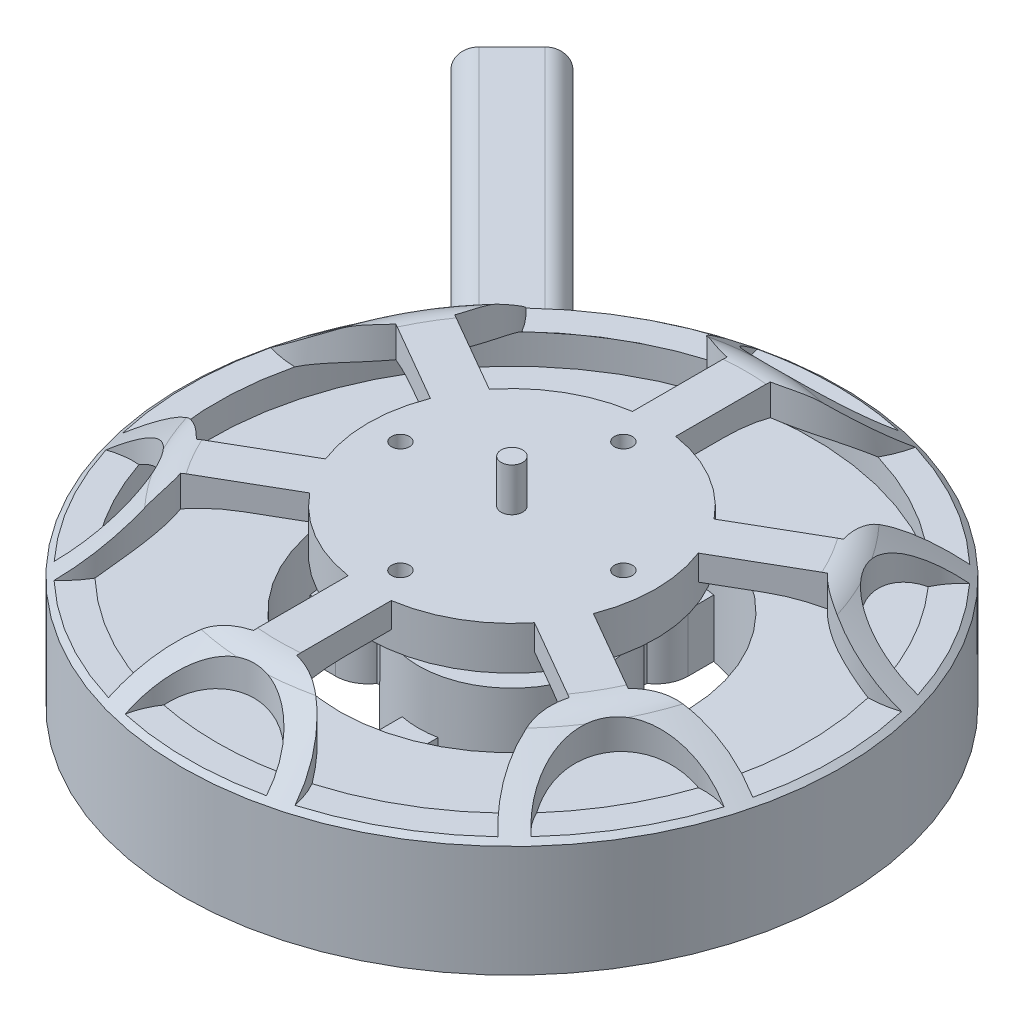
from build123d import *

# Parameters (mm, degrees)
M4X0_7_TAPPED_HOLE1_D     = 3.3
M4X0_7_TAPPED_HOLE1_DEPTH = 8.000009
M4X0_7_TAPPED_HOLE1_TIP   = 0.99142
CUT_EXTRUDE1_DEPTH        = 8
CUT_EXTRUDE3_START        = 32.18
SKETCH6_OUTSIDE_W         = 120.686
SKETCH6_OUTSIDE_H         = 120.686
CUT_EXTRUDE3_DEPTH        = 8
M3X0_5_TAPPED_HOLE1_D     = 2.5
M3X0_5_TAPPED_HOLE1_DEPTH = 6
BOSS_EXTRUDE1_START       = 12.7
BOSS_EXTRUDE1_DEPTH       = 19.05


with BuildPart() as part:
    # Sketch1 → Revolve1 (revolve)
    with BuildSketch(Plane.XY):
        with BuildLine():
            Line((0, 0), (9.65, 0))
            Line((9.65, 0), (9.65, 3.93))
            Line((9.65, 3.93), (27.5, 3.93))
            Line((27.5, 3.93), (45.83, 8.08))
            Line((45.83, 8.08), (45.83, 23.58))
            Line((45.83, 23.58), (36.13217, 30.955703))
            ThreePointArc((36.13217, 30.955703), (34.416479, 31.865693), (32.5, 32.18))
            Line((32.5, 32.18), (1.5, 32.18))
            Line((1.5, 32.18), (1.5, 38.18))
            Line((1.5, 38.18), (0, 38.18))
            Line((0, 38.18), (0, 0))
        make_face()
    revolve(axis=Axis((0, 38.18, 0), (0, -1, 0)))

    # M4x0.7 Tapped Hole1
    with Locations(Plane(origin=(-20, 3.93, 0), x_dir=(0, 0, -1), z_dir=(0, -1, 0))):
        with Locations((0, 0), (-20, 20), (0, 40), (20, 20)):
            Hole(M4X0_7_TAPPED_HOLE1_D / 2, depth=M4X0_7_TAPPED_HOLE1_DEPTH)
            with Locations((0, 0, -(M4X0_7_TAPPED_HOLE1_DEPTH + M4X0_7_TAPPED_HOLE1_TIP / 2))):  # 118° drill point
                Cone(0, M4X0_7_TAPPED_HOLE1_D / 2, M4X0_7_TAPPED_HOLE1_TIP, mode=Mode.SUBTRACT)

    # Sketch2 → Cut-Extrude1 (cut)
    with BuildSketch(Plane.XZ.offset(-3.93)):
        with BuildLine():
            Line((2.5, 12.757351), (2.5, 16.258343))
            ThreePointArc((2.5, 16.258343), (3.968627, 17.87868), (4.5, 20))
            Line((4.5, 20), (4.5, 23.57435))
            ThreePointArc((4.5, 23.57435), (16.970563, 16.970563), (23.57435, 4.5))
            Line((23.57435, 4.5), (20, 4.5))
            ThreePointArc((20, 4.5), (17.87868, 3.968627), (16.258343, 2.5))
            Line((16.258343, 2.5), (12.757351, 2.5))
            ThreePointArc((12.757351, 2.5), (9.192388, 9.192388), (2.5, 12.757351))
        make_face()
        with BuildLine():
            Line((20, -4.5), (23.57435, -4.5))
            ThreePointArc((23.57435, -4.5), (16.970563, -16.970563), (4.5, -23.57435))
            Line((4.5, -23.57435), (4.5, -20))
            ThreePointArc((4.5, -20), (3.968627, -17.87868), (2.5, -16.258343))
            Line((2.5, -16.258343), (2.5, -12.757351))
            ThreePointArc((2.5, -12.757351), (9.192388, -9.192388), (12.757351, -2.5))
            Line((12.757351, -2.5), (16.258343, -2.5))
            ThreePointArc((16.258343, -2.5), (17.87868, -3.968627), (20, -4.5))
        make_face()
        with BuildLine():
            Line((-4.5, -20), (-4.5, -23.57435))
            ThreePointArc((-4.5, -23.57435), (-16.970563, -16.970563), (-23.57435, -4.5))
            Line((-23.57435, -4.5), (-20, -4.5))
            ThreePointArc((-20, -4.5), (-17.87868, -3.968627), (-16.258343, -2.5))
            Line((-16.258343, -2.5), (-12.757351, -2.5))
            ThreePointArc((-12.757351, -2.5), (-9.192388, -9.192388), (-2.5, -12.757351))
            Line((-2.5, -12.757351), (-2.5, -16.258343))
            ThreePointArc((-2.5, -16.258343), (-3.968627, -17.87868), (-4.5, -20))
        make_face()
        with BuildLine():
            Line((-20, 4.5), (-23.57435, 4.5))
            ThreePointArc((-23.57435, 4.5), (-16.970563, 16.970563), (-4.5, 23.57435))
            Line((-4.5, 23.57435), (-4.5, 20))
            ThreePointArc((-4.5, 20), (-3.968627, 17.87868), (-2.5, 16.258343))
            Line((-2.5, 16.258343), (-2.5, 12.757351))
            ThreePointArc((-2.5, 12.757351), (-9.192388, 9.192388), (-12.757351, 2.5))
            Line((-12.757351, 2.5), (-16.258343, 2.5))
            ThreePointArc((-16.258343, 2.5), (-17.87868, 3.968627), (-20, 4.5))
        make_face()
    extrude(amount=-CUT_EXTRUDE1_DEPTH, mode=Mode.SUBTRACT)

    # Sketch5 → Cut-Revolve3 (revolve, cut)
    with BuildSketch(Plane.XY):
        with BuildLine():
            Line((24, 19.43), (41.83, 19.43))
            Line((41.83, 19.43), (41.83, 23.58))
            ThreePointArc((41.83, 23.58), (34.683019, 27.370707), (26.699628, 28.68))
            Line((26.699628, 28.68), (20, 28.68))
            Line((20, 28.68), (20, 26.18))
            Line((20, 26.18), (10, 26.18))
            Line((10, 26.18), (10, 19.43))
            Line((10, 19.43), (13, 19.43))
            Line((13, 19.43), (13, 11.93))
            Line((13, 11.93), (24, 11.93))
            Line((24, 11.93), (24, 19.43))
        make_face()
    revolve(axis=Axis((0, 40.089, 0), (0, -1, 0)), mode=Mode.SUBTRACT)

    # Sketch6 outside → Cut-Extrude3 (cut)
    with BuildSketch(Plane(origin=(0, 0, 0), x_dir=(1, 0, 0), z_dir=(0, 1, 0)).offset(CUT_EXTRUDE3_START)):
        Rectangle(SKETCH6_OUTSIDE_W, SKETCH6_OUTSIDE_H)
        with BuildLine():
            Line((-3, 19.77372), (-3, 32.924091))
            ThreePointArc((-3, 32.924091), (-9.751293, 36.859226), (-13.11083, 43.914633))
            ThreePointArc((-13.11083, 43.914633), (-11.532938, 44.35516), (-9.940309, 44.739012))
            ThreePointArc((-9.940309, 44.739012), (0, 35.83), (9.940309, 44.739012))
            ThreePointArc((9.940309, 44.739012), (11.532938, 44.35516), (13.11083, 43.914633))
            ThreePointArc((13.11083, 43.914633), (9.751293, 36.859226), (3, 32.924091))
            Line((3, 32.924091), (3, 19.77372))
            ThreePointArc((3, 19.77372), (10, 17.320508), (15.624544, 12.484936))
            Line((15.624544, 12.484936), (27.013099, 19.060121))
            ThreePointArc((27.013099, 19.060121), (27.04538, 26.874481), (31.475773, 33.311629))
            ThreePointArc((31.475773, 33.311629), (32.646227, 32.165397), (33.774966, 30.978066))
            ThreePointArc((33.774966, 30.978066), (31.02969, 17.915), (43.715275, 13.760946))
            ThreePointArc((43.715275, 13.760946), (44.179165, 12.189763), (44.586603, 10.603005))
            ThreePointArc((44.586603, 10.603005), (36.796673, 9.984745), (30.013099, 13.863969))
            Line((30.013099, 13.863969), (18.624544, 7.288784))
            ThreePointArc((18.624544, 7.288784), (20, 0), (18.624544, -7.288784))
            Line((18.624544, -7.288784), (30.013099, -13.863969))
            ThreePointArc((30.013099, -13.863969), (36.796673, -9.984745), (44.586603, -10.603005))
            ThreePointArc((44.586603, -10.603005), (44.179165, -12.189763), (43.715275, -13.760946))
            ThreePointArc((43.715275, -13.760946), (31.02969, -17.915), (33.774966, -30.978066))
            ThreePointArc((33.774966, -30.978066), (32.646227, -32.165397), (31.475773, -33.311629))
            ThreePointArc((31.475773, -33.311629), (27.04538, -26.874481), (27.013099, -19.060121))
            Line((27.013099, -19.060121), (15.624544, -12.484936))
            ThreePointArc((15.624544, -12.484936), (10, -17.320508), (3, -19.77372))
            Line((3, -19.77372), (3, -32.924091))
            ThreePointArc((3, -32.924091), (9.751293, -36.859226), (13.11083, -43.914633))
            ThreePointArc((13.11083, -43.914633), (11.532938, -44.35516), (9.940309, -44.739012))
            ThreePointArc((9.940309, -44.739012), (0, -35.83), (-9.940309, -44.739012))
            ThreePointArc((-9.940309, -44.739012), (-11.532938, -44.35516), (-13.11083, -43.914633))
            ThreePointArc((-13.11083, -43.914633), (-9.751293, -36.859226), (-3, -32.924091))
            Line((-3, -32.924091), (-3, -19.77372))
            ThreePointArc((-3, -19.77372), (-10, -17.320508), (-15.624544, -12.484936))
            Line((-15.624544, -12.484936), (-27.013099, -19.060121))
            ThreePointArc((-27.013099, -19.060121), (-27.04538, -26.874481), (-31.475773, -33.311629))
            ThreePointArc((-31.475773, -33.311629), (-32.646227, -32.165397), (-33.774966, -30.978066))
            ThreePointArc((-33.774966, -30.978066), (-31.02969, -17.915), (-43.715275, -13.760946))
            ThreePointArc((-43.715275, -13.760946), (-44.179165, -12.189763), (-44.586603, -10.603005))
            ThreePointArc((-44.586603, -10.603005), (-36.796673, -9.984745), (-30.013099, -13.863969))
            Line((-30.013099, -13.863969), (-18.624544, -7.288784))
            ThreePointArc((-18.624544, -7.288784), (-20, 0), (-18.624544, 7.288784))
            Line((-18.624544, 7.288784), (-30.013099, 13.863969))
            ThreePointArc((-30.013099, 13.863969), (-36.796673, 9.984745), (-44.586603, 10.603005))
            ThreePointArc((-44.586603, 10.603005), (-44.179165, 12.189763), (-43.715275, 13.760946))
            ThreePointArc((-43.715275, 13.760946), (-31.02969, 17.915), (-33.774966, 30.978066))
            ThreePointArc((-33.774966, 30.978066), (-32.646227, 32.165397), (-31.475773, 33.311629))
            ThreePointArc((-31.475773, 33.311629), (-27.04538, 26.874481), (-27.013099, 19.060121))
            Line((-27.013099, 19.060121), (-15.624544, 12.484936))
            ThreePointArc((-15.624544, 12.484936), (-10, 17.320508), (-3, 19.77372))
        make_face(mode=Mode.SUBTRACT)
    extrude(amount=-CUT_EXTRUDE3_DEPTH, mode=Mode.SUBTRACT)

    # M3x0.5 Tapped Hole1
    with Locations(Plane(origin=(0, 32.18, 0), x_dir=(1, 0, 0), z_dir=(0, 1, 0))):
        with Locations((0, 15.5), (15.5, 0), (0, -15.5), (-15.5, 0)):
            Hole(M3X0_5_TAPPED_HOLE1_D / 2, depth=M3X0_5_TAPPED_HOLE1_DEPTH)

    # Sketch11 → Boss-Extrude1 (add)
    with BuildSketch(Plane(origin=(0, 0, 0), x_dir=(1, 0, 0), z_dir=(0, 1, 0)).offset(BOSS_EXTRUDE1_START)):
        with BuildLine():
            Line((-27.987286, 23.391092), (-23.391092, 27.987286))
            ThreePointArc((-23.391092, 27.987286), (-19.502005, 27.987286), (-19.502005, 24.098199))
            Line((-19.502005, 24.098199), (-24.098199, 19.502005))
            ThreePointArc((-24.098199, 19.502005), (-27.987286, 19.502005), (-27.987286, 23.391092))
        make_face()
    extrude(amount=-BOSS_EXTRUDE1_DEPTH)

    # Sweep1: sweep along a path in Sketch12
    with BuildLine(Plane(origin=(0, 0, 0), x_dir=(0.707107, 0, 0.707107), z_dir=(-0.707107, 0, 0.707107))) as sweep1_path:
        Line((-150.63, -19.05), (-49.03, -19.05))
        ThreePointArc((-49.03, -19.05), (-40.049744, -15.330256), (-36.33, -6.35))
    # Sketch13 → Sweep1 (sweep)
    with BuildSketch(Plane.XZ.offset(6.35)):
        with BuildLine():
            Line((-27.987286, -23.391092), (-23.391092, -27.987286))
            ThreePointArc((-23.391092, -27.987286), (-19.502005, -27.987286), (-19.502005, -24.098199))
            Line((-19.502005, -24.098199), (-24.098199, -19.502005))
            ThreePointArc((-24.098199, -19.502005), (-27.987286, -19.502005), (-27.987286, -23.391092))
        make_face()
    sweep(path=sweep1_path.line)


solid = part.part
